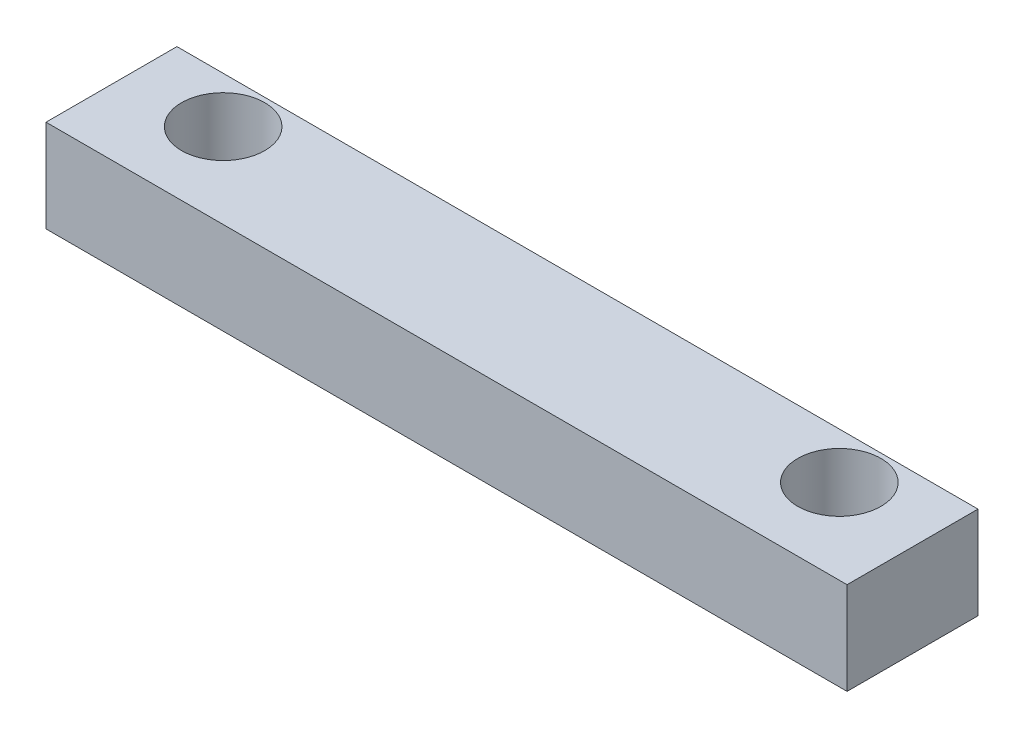
from build123d import *

# Parameters (mm, degrees)
SKETCH1_W           = 26
SKETCH1_H           = 18
BOSS_EXTRUDE1_DEPTH = 13
SKETCH2_R           = 1.35
CUT_EXTRUDE1_DEPTH  = 14
SKETCH3_W           = 26
SKETCH3_H           = 13.75
CUT_EXTRUDE3_DEPTH  = 14
SKETCH4_W           = 26
SKETCH4_H           = 10
CUT_EXTRUDE4_DEPTH  = 5.25


with BuildPart() as part:
    # Sketch1 → Boss-Extrude1 (new body)
    with BuildSketch(Plane(origin=(0, 0, 0), x_dir=(1, 0, 0), z_dir=(0, 1, 0))):
        with Locations((13, 9)):
            Rectangle(SKETCH1_W, SKETCH1_H)
    extrude(amount=BOSS_EXTRUDE1_DEPTH)

    # Sketch2 → Cut-Extrude1 (cut, through all)
    with BuildSketch(Plane(origin=(0, 13, 0), x_dir=(1, 0, 0), z_dir=(0, 1, 0))):
        with Locations((3, 15.25)):
            Circle(SKETCH2_R)
        with Locations((23, 15.25)):
            Circle(SKETCH2_R)
        with Locations((3, 2.75)):
            Circle(SKETCH2_R)
        with Locations((23, 2.75)):
            Circle(SKETCH2_R)
    extrude(amount=-CUT_EXTRUDE1_DEPTH, mode=Mode.SUBTRACT)

    # Sketch3 → Cut-Extrude3 (cut, through all)
    with BuildSketch(Plane(origin=(0, 13, 0), x_dir=(1, 0, 0), z_dir=(0, 1, 0))):
        with Locations((13, 11.125)):
            Rectangle(SKETCH3_W, SKETCH3_H)
    extrude(amount=-CUT_EXTRUDE3_DEPTH, mode=Mode.SUBTRACT)

    # Sketch4 → Cut-Extrude4 (cut, through all)
    with BuildSketch(Plane.XY):
        with Locations((13, 5)):
            Rectangle(SKETCH4_W, SKETCH4_H)
    extrude(amount=-CUT_EXTRUDE4_DEPTH, mode=Mode.SUBTRACT)


solid = part.part
